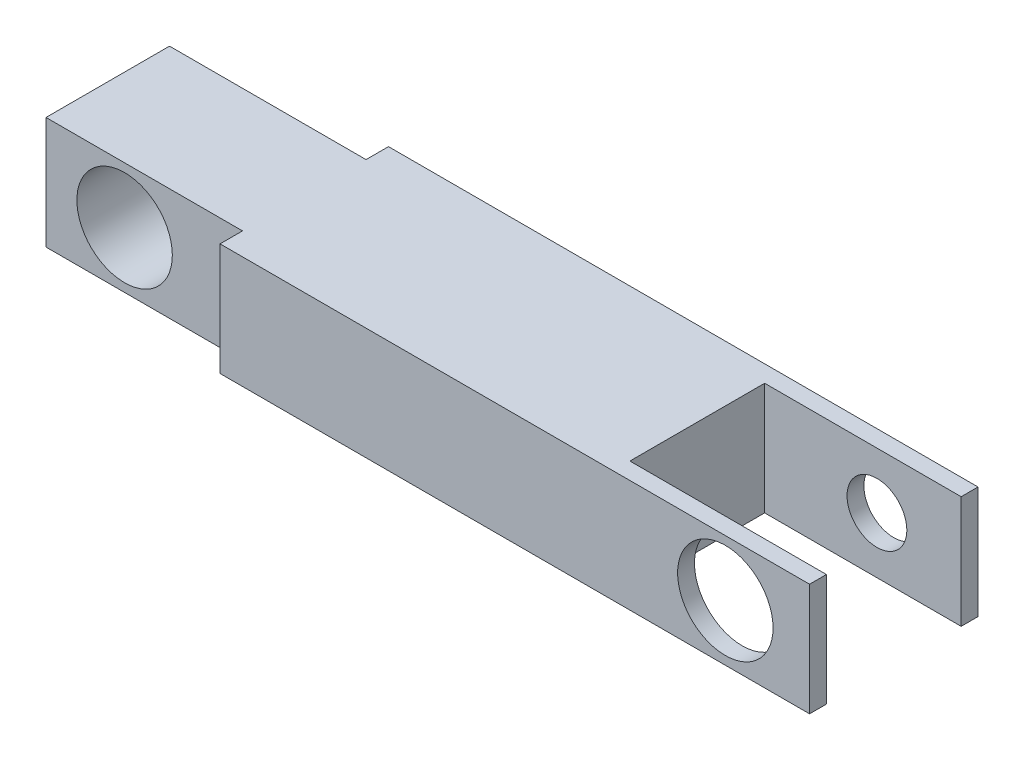
from build123d import *

# Parameters (mm, degrees)
SKETCH2_W                 = 35.56
SKETCH2_H                 = 5.08
BOSS_EXTRUDE1_DEPTH       = 7.62
SKETCH7_W                 = 8.89
SKETCH7_H                 = 6.096
SKETCH7_H_2               = 1.016
CUT_EXTRUDE2_DEPTH        = 6.08
CUT_EXTRUDE3_REACH        = 9.62
SKETCH8_R                 = 2.159
SKETCH9_R                 = 2.159
CUT_EXTRUDE4_DEPTH        = 7.604
F_6_32_TAPPED_HOLE1_D     = 2.7051
F_6_32_TAPPED_HOLE1_DEPTH = 0.762


with BuildPart() as part:
    # Sketch2 → Boss-Extrude1 (new body)
    with BuildSketch(Plane.XY):
        with Locations((-54.739863719, -4.815217495)):
            Rectangle(SKETCH2_W, SKETCH2_H)
    extrude(amount=BOSS_EXTRUDE1_DEPTH)

    # Sketch7 → Cut-Extrude2 (cut, through all)
    with BuildSketch(Plane.XZ.offset(7.355217495)):
        with Locations((-41.404863719, 3.81)):
            Rectangle(SKETCH7_W, SKETCH7_H)
        with Locations((-68.074863719, 0.508)):
            Rectangle(SKETCH7_W, SKETCH7_H_2)
        with Locations((-68.074863719, 7.112)):
            Rectangle(SKETCH7_W, SKETCH7_H_2)
    extrude(amount=-CUT_EXTRUDE2_DEPTH, mode=Mode.SUBTRACT)

    # Sketch8 → Cut-Extrude3 (cut, up to next)
    with BuildSketch(Plane.XY.offset(7.62), mode=Mode.PRIVATE) as cut_extrude3_sk1:
        with Locations((-40.769863719, -4.815217495)):
            Circle(SKETCH8_R)
    cut_extrude3_tool1 = extrude(cut_extrude3_sk1.sketch, amount=-CUT_EXTRUDE3_REACH, mode=Mode.PRIVATE) & part.part
    add(cut_extrude3_tool1.solids().sort_by_distance((-40.769864, -4.815217, 7.62))[0], mode=Mode.SUBTRACT)

    # Sketch9 → Cut-Extrude4 (cut, through all)
    with BuildSketch(Plane.XY.offset(6.604)):
        with Locations((-68.963863719, -4.815217495)):
            Circle(SKETCH9_R)
    extrude(amount=-CUT_EXTRUDE4_DEPTH, mode=Mode.SUBTRACT)

    # #6-32 Tapped Hole1
    with Locations(Plane(origin=(0, 0, 0), x_dir=(-1, 0, 0), z_dir=(0, 0, -1))):
        with Locations((40.769863719, -4.815217495)):
            Hole(F_6_32_TAPPED_HOLE1_D / 2, depth=F_6_32_TAPPED_HOLE1_DEPTH)


solid = part.part
